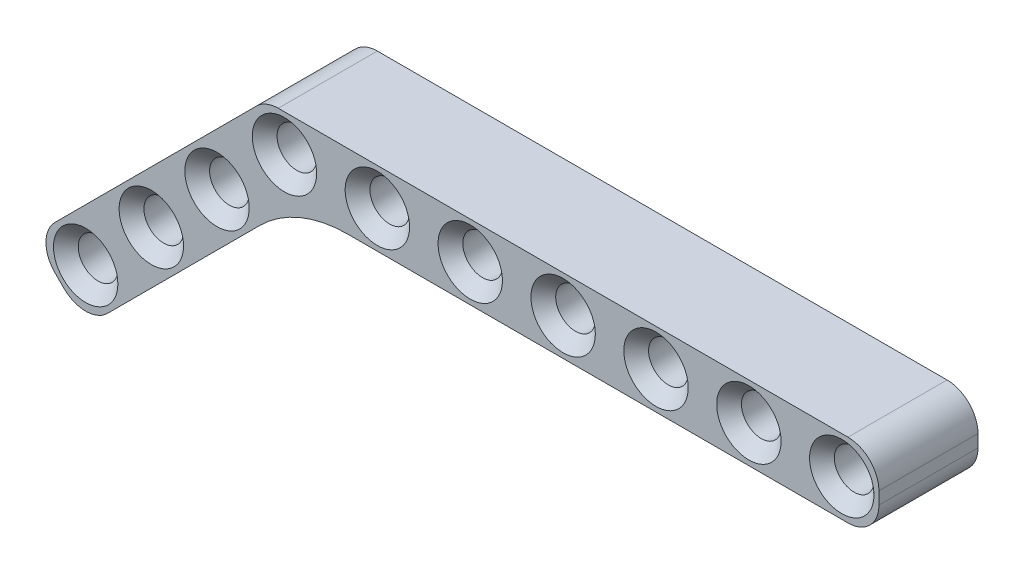
from build123d import *

# Parameters (mm, degrees)
SKETCH1_R           = 1.6
BOSS_EXTRUDE1_DEPTH = 8
CHAMFER1_SIZE       = 1
SKETCH2_R           = 1.6
BOSS_EXTRUDE3_DEPTH = 8
FILLET1_R           = 10
CHAMFER2_SIZE       = 1
CHAMFER3_SIZE       = 1


with BuildPart() as part:
    # Sketch1 → Boss-Extrude1 (new body)
    with BuildSketch(Plane.XY):
        with BuildLine():
            Line((-0.5, 3), (45.5, 3))
            ThreePointArc((45.5, 3), (47.267766953, 2.267766953), (48, 0.5))
            Line((48, 0.5), (48, -0.5))
            ThreePointArc((48, -0.5), (47.267766953, -2.267766953), (45.5, -3))
            Line((45.5, -3), (-0.5, -3))
            ThreePointArc((-0.5, -3), (-2.267766953, -2.267766953), (-3, -0.5))
            Line((-3, -0.5), (-3, 0.5))
            ThreePointArc((-3, 0.5), (-2.267766953, 2.267766953), (-0.5, 3))
        make_face()
        Circle(SKETCH1_R, mode=Mode.SUBTRACT)
        with Locations((7.5, 0)):
            Circle(SKETCH1_R, mode=Mode.SUBTRACT)
        with Locations((15, 0)):
            Circle(SKETCH1_R, mode=Mode.SUBTRACT)
        with Locations((22.5, 0)):
            Circle(SKETCH1_R, mode=Mode.SUBTRACT)
        with Locations((30, 0)):
            Circle(SKETCH1_R, mode=Mode.SUBTRACT)
        with Locations((37.5, 0)):
            Circle(SKETCH1_R, mode=Mode.SUBTRACT)
        with Locations((45, 0)):
            Circle(SKETCH1_R, mode=Mode.SUBTRACT)
    extrude(amount=BOSS_EXTRUDE1_DEPTH)

    # Chamfer1
    chamfer1_edges = [part.edges().sort_by_distance(p)[0] for p in [
        (-1.6, 0, 0),
        (-1.6, 0, 8),
        (5.9, 0, 0),
        (5.9, 0, 8),
        (13.4, 0, 0),
        (13.4, 0, 8),
        (20.9, 0, 0),
        (20.9, 0, 8),
        (28.4, 0, 0),
        (28.4, 0, 8),
    ]]
    chamfer(chamfer1_edges, length=CHAMFER1_SIZE)

    # Sketch2 → Boss-Extrude3 (add)
    with BuildSketch(Plane.XY.offset(8)):
        with BuildLine():
            ThreePointArc((-3, 0.5), (-2.809698831, 1.456708581), (-2.267766953, 2.267766953))
            Line((-2.267766953, 2.267766953), (-18.529200529, -13.993666623))
            ThreePointArc((-18.529200529, -13.993666623), (-19.261433576, -15.761433576), (-18.529200529, -17.529200529))
            Line((-18.529200529, -17.529200529), (-17.822093748, -18.23630731))
            ThreePointArc((-17.822093748, -18.23630731), (-16.054326795, -18.968540357), (-14.286559842, -18.23630731))
            Line((-14.286559842, -18.23630731), (0.949747468, -3))
            Line((0.949747468, -3), (-0.5, -3))
            ThreePointArc((-0.5, -3), (-2.267766953, -2.267766953), (-3, -0.5))
            Line((-3, -0.5), (-3, 0.5))
        make_face()
        with Locations((-16.054326795, -15.761433576)):
            Circle(SKETCH2_R, mode=Mode.SUBTRACT)
        with Locations((-10.751025936, -10.458132717)):
            Circle(SKETCH2_R, mode=Mode.SUBTRACT)
        with Locations((-5.447725077, -5.154831858)):
            Circle(SKETCH2_R, mode=Mode.SUBTRACT)
    extrude(amount=-BOSS_EXTRUDE3_DEPTH)

    # Fillet1
    fillet1_edges = [part.edges().sort_by_distance(p)[0] for p in [
        (0.949747468, -3, 4),
    ]]
    fillet(fillet1_edges, radius=FILLET1_R)

    # Chamfer2
    chamfer2_edges = [part.edges().sort_by_distance(p)[0] for p in [
        (-17.654326795, -15.761433576, 8),
        (-12.351025936, -10.458132717, 8),
        (-7.047725077, -5.154831858, 8),
        (-7.047725077, -5.154831858, 0),
        (-12.351025936, -10.458132717, 0),
        (-17.654326795, -15.761433576, 0),
    ]]
    chamfer(chamfer2_edges, length=CHAMFER2_SIZE)

    # Chamfer3
    chamfer3_edges = [part.edges().sort_by_distance(p)[0] for p in [
        (35.9, 0, 0),
        (35.9, 0, 8),
        (43.4, 0, 0),
        (43.4, 0, 8),
    ]]
    chamfer(chamfer3_edges, length=CHAMFER3_SIZE)


solid = part.part
